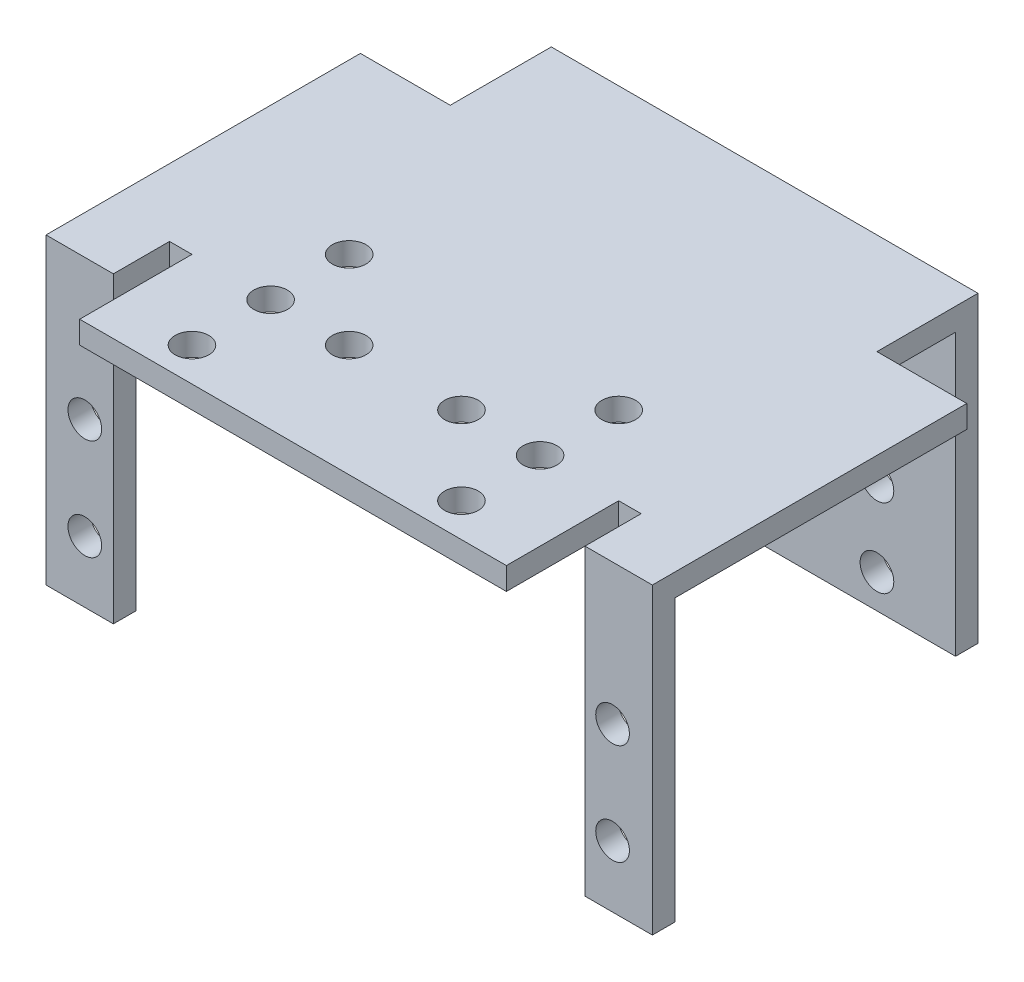
from build123d import *

# Parameters (mm, degrees)
SKETCH1_W           = 19
SKETCH1_H           = 27
BOSS_EXTRUDE1_DEPTH = 2
SKETCH2_W           = 19
SKETCH2_H           = 2
BOSS_EXTRUDE2_DEPTH = 40
BOSS_EXTRUDE3_DEPTH = 2
SKETCH5_W           = 6
SKETCH5_H           = 2
BOSS_EXTRUDE4_DEPTH = 25
SKETCH6_R           = 1.5
CUT_EXTRUDE1_DEPTH  = 2
CUT_EXTRUDE2_REACH  = 9
SKETCH7_R           = 1.5
CUT_EXTRUDE4_REACH  = 29
SKETCH9_R           = 1.5


with BuildPart() as part:
    # Sketch1 → Boss-Extrude1 (new body)
    with BuildSketch(Plane.XY):
        with Locations((9.5, 13.5)):
            Rectangle(SKETCH1_W, SKETCH1_H)
    boss_extrude1 = extrude(amount=BOSS_EXTRUDE1_DEPTH)

    # Sketch2 → Boss-Extrude2 (add)
    with BuildSketch(Plane.XY.offset(2)):
        with Locations((9.5, 26)):
            Rectangle(SKETCH2_W, SKETCH2_H)
    boss_extrude2 = extrude(amount=BOSS_EXTRUDE2_DEPTH)

    # Sketch3 → Boss-Extrude3 (add)
    with BuildSketch(Plane(origin=(0, 25, 0), x_dir=(-1, 0, 0), z_dir=(0, -1, 0))):
        Polygon((-19, -32), (-19, -9), (-27, -9), (-27, -37), (-21, -37), (-21, -32), align=None)
    boss_extrude3 = extrude(amount=-BOSS_EXTRUDE3_DEPTH)

    # Sketch5 → Boss-Extrude4 (add)
    with BuildSketch(Plane(origin=(0, 25, 0), x_dir=(-1, 0, 0), z_dir=(0, -1, 0))):
        with Locations((-24, -36)):
            Rectangle(SKETCH5_W, SKETCH5_H)
    boss_extrude4 = extrude(amount=BOSS_EXTRUDE4_DEPTH)

    # Sketch6 → Cut-Extrude1 (cut)
    with BuildSketch(Plane.XY.offset(2)):
        with Locations((12, 3)):
            Circle(SKETCH6_R)
        with Locations((12, 10)):
            Circle(SKETCH6_R)
        with Locations((12, 17)):
            Circle(SKETCH6_R)
        with Locations((5, 10)):
            Circle(SKETCH6_R)
    cut_extrude1 = extrude(amount=-CUT_EXTRUDE1_DEPTH, mode=Mode.SUBTRACT)

    # Mirror2: Boss-Extrude1, Boss-Extrude2, Boss-Extrude3, Boss-Extrude4, Cut-Extrude1 across plane
    add(boss_extrude1.mirror(Plane(origin=(0, 0, 2), x_dir=(0, 0, 1), z_dir=(1, 0, 0))))
    add(boss_extrude2.mirror(Plane(origin=(0, 0, 2), x_dir=(0, 0, 1), z_dir=(1, 0, 0))))
    add(boss_extrude3.mirror(Plane(origin=(0, 0, 2), x_dir=(0, 0, 1), z_dir=(1, 0, 0))))
    add(boss_extrude4.mirror(Plane(origin=(0, 0, 2), x_dir=(0, 0, 1), z_dir=(1, 0, 0))))
    add(cut_extrude1.mirror(Plane(origin=(0, 0, 2), x_dir=(0, 0, 1), z_dir=(1, 0, 0))), mode=Mode.SUBTRACT)

    # Sketch7 → Cut-Extrude2 (cut, up to next)
    with BuildSketch(Plane(origin=(0, 0, 35), x_dir=(-1, 0, 0), z_dir=(0, 0, -1)), mode=Mode.PRIVATE) as cut_extrude2_sk1:
        with Locations((-23.456279898, 5.5)):
            Circle(SKETCH7_R)
    cut_extrude2_tool1 = extrude(cut_extrude2_sk1.sketch, amount=-CUT_EXTRUDE2_REACH, mode=Mode.PRIVATE) & part.part
    add(cut_extrude2_tool1.solids().sort_by_distance((23.45628, 5.5, 35))[0], mode=Mode.SUBTRACT)
    # Sketch7 → Cut-Extrude2 (cut, up to next)
    with BuildSketch(Plane(origin=(0, 0, 35), x_dir=(-1, 0, 0), z_dir=(0, 0, -1)), mode=Mode.PRIVATE) as cut_extrude2_sk2:
        with Locations((-23.456279898, 14.5)):
            Circle(SKETCH7_R)
    cut_extrude2_tool2 = extrude(cut_extrude2_sk2.sketch, amount=-CUT_EXTRUDE2_REACH, mode=Mode.PRIVATE) & part.part
    add(cut_extrude2_tool2.solids().sort_by_distance((23.45628, 14.5, 35))[0], mode=Mode.SUBTRACT)
    # Sketch7 → Cut-Extrude2 (cut, up to next)
    with BuildSketch(Plane(origin=(0, 0, 35), x_dir=(-1, 0, 0), z_dir=(0, 0, -1)), mode=Mode.PRIVATE) as cut_extrude2_sk3:
        with Locations((23.543720102, 5.5)):
            Circle(SKETCH7_R)
    cut_extrude2_tool3 = extrude(cut_extrude2_sk3.sketch, amount=-CUT_EXTRUDE2_REACH, mode=Mode.PRIVATE) & part.part
    add(cut_extrude2_tool3.solids().sort_by_distance((-23.54372, 5.5, 35))[0], mode=Mode.SUBTRACT)
    # Sketch7 → Cut-Extrude2 (cut, up to next)
    with BuildSketch(Plane(origin=(0, 0, 35), x_dir=(-1, 0, 0), z_dir=(0, 0, -1)), mode=Mode.PRIVATE) as cut_extrude2_sk4:
        with Locations((23.543720102, 14.5)):
            Circle(SKETCH7_R)
    cut_extrude2_tool4 = extrude(cut_extrude2_sk4.sketch, amount=-CUT_EXTRUDE2_REACH, mode=Mode.PRIVATE) & part.part
    add(cut_extrude2_tool4.solids().sort_by_distance((-23.54372, 14.5, 35))[0], mode=Mode.SUBTRACT)

    # Sketch9 → Cut-Extrude4 (cut, up to next)
    with BuildSketch(Plane(origin=(0, 27, 0), x_dir=(1, 0, 0), z_dir=(0, 1, 0)), mode=Mode.PRIVATE) as cut_extrude4_sk1:
        with Locations((12, -32)):
            Circle(SKETCH9_R)
    cut_extrude4_tool1 = extrude(cut_extrude4_sk1.sketch, amount=-CUT_EXTRUDE4_REACH, mode=Mode.PRIVATE) & part.part
    add(cut_extrude4_tool1.solids().sort_by_distance((12, 27, 32))[0], mode=Mode.SUBTRACT)
    # Sketch9 → Cut-Extrude4 (cut, up to next)
    with BuildSketch(Plane(origin=(0, 27, 0), x_dir=(1, 0, 0), z_dir=(0, 1, 0)), mode=Mode.PRIVATE) as cut_extrude4_sk2:
        with Locations((12, -25)):
            Circle(SKETCH9_R)
    cut_extrude4_tool2 = extrude(cut_extrude4_sk2.sketch, amount=-CUT_EXTRUDE4_REACH, mode=Mode.PRIVATE) & part.part
    add(cut_extrude4_tool2.solids().sort_by_distance((12, 27, 25))[0], mode=Mode.SUBTRACT)
    # Sketch9 → Cut-Extrude4 (cut, up to next)
    with BuildSketch(Plane(origin=(0, 27, 0), x_dir=(1, 0, 0), z_dir=(0, 1, 0)), mode=Mode.PRIVATE) as cut_extrude4_sk3:
        with Locations((12, -39)):
            Circle(SKETCH9_R)
    cut_extrude4_tool3 = extrude(cut_extrude4_sk3.sketch, amount=-CUT_EXTRUDE4_REACH, mode=Mode.PRIVATE) & part.part
    add(cut_extrude4_tool3.solids().sort_by_distance((12, 27, 39))[0], mode=Mode.SUBTRACT)
    # Sketch9 → Cut-Extrude4 (cut, up to next)
    with BuildSketch(Plane(origin=(0, 27, 0), x_dir=(1, 0, 0), z_dir=(0, 1, 0)), mode=Mode.PRIVATE) as cut_extrude4_sk4:
        with Locations((5, -32)):
            Circle(SKETCH9_R)
    cut_extrude4_tool4 = extrude(cut_extrude4_sk4.sketch, amount=-CUT_EXTRUDE4_REACH, mode=Mode.PRIVATE) & part.part
    add(cut_extrude4_tool4.solids().sort_by_distance((5, 27, 32))[0], mode=Mode.SUBTRACT)
    # Sketch9 → Cut-Extrude4 (cut, up to next)
    with BuildSketch(Plane(origin=(0, 27, 0), x_dir=(1, 0, 0), z_dir=(0, 1, 0)), mode=Mode.PRIVATE) as cut_extrude4_sk5:
        with Locations((-5, -32)):
            Circle(SKETCH9_R)
    cut_extrude4_tool5 = extrude(cut_extrude4_sk5.sketch, amount=-CUT_EXTRUDE4_REACH, mode=Mode.PRIVATE) & part.part
    add(cut_extrude4_tool5.solids().sort_by_distance((-5, 27, 32))[0], mode=Mode.SUBTRACT)
    # Sketch9 → Cut-Extrude4 (cut, up to next)
    with BuildSketch(Plane(origin=(0, 27, 0), x_dir=(1, 0, 0), z_dir=(0, 1, 0)), mode=Mode.PRIVATE) as cut_extrude4_sk6:
        with Locations((-12, -32)):
            Circle(SKETCH9_R)
    cut_extrude4_tool6 = extrude(cut_extrude4_sk6.sketch, amount=-CUT_EXTRUDE4_REACH, mode=Mode.PRIVATE) & part.part
    add(cut_extrude4_tool6.solids().sort_by_distance((-12, 27, 32))[0], mode=Mode.SUBTRACT)
    # Sketch9 → Cut-Extrude4 (cut, up to next)
    with BuildSketch(Plane(origin=(0, 27, 0), x_dir=(1, 0, 0), z_dir=(0, 1, 0)), mode=Mode.PRIVATE) as cut_extrude4_sk7:
        with Locations((-12, -39)):
            Circle(SKETCH9_R)
    cut_extrude4_tool7 = extrude(cut_extrude4_sk7.sketch, amount=-CUT_EXTRUDE4_REACH, mode=Mode.PRIVATE) & part.part
    add(cut_extrude4_tool7.solids().sort_by_distance((-12, 27, 39))[0], mode=Mode.SUBTRACT)
    # Sketch9 → Cut-Extrude4 (cut, up to next)
    with BuildSketch(Plane(origin=(0, 27, 0), x_dir=(1, 0, 0), z_dir=(0, 1, 0)), mode=Mode.PRIVATE) as cut_extrude4_sk8:
        with Locations((-12, -25)):
            Circle(SKETCH9_R)
    cut_extrude4_tool8 = extrude(cut_extrude4_sk8.sketch, amount=-CUT_EXTRUDE4_REACH, mode=Mode.PRIVATE) & part.part
    add(cut_extrude4_tool8.solids().sort_by_distance((-12, 27, 25))[0], mode=Mode.SUBTRACT)


solid = part.part
